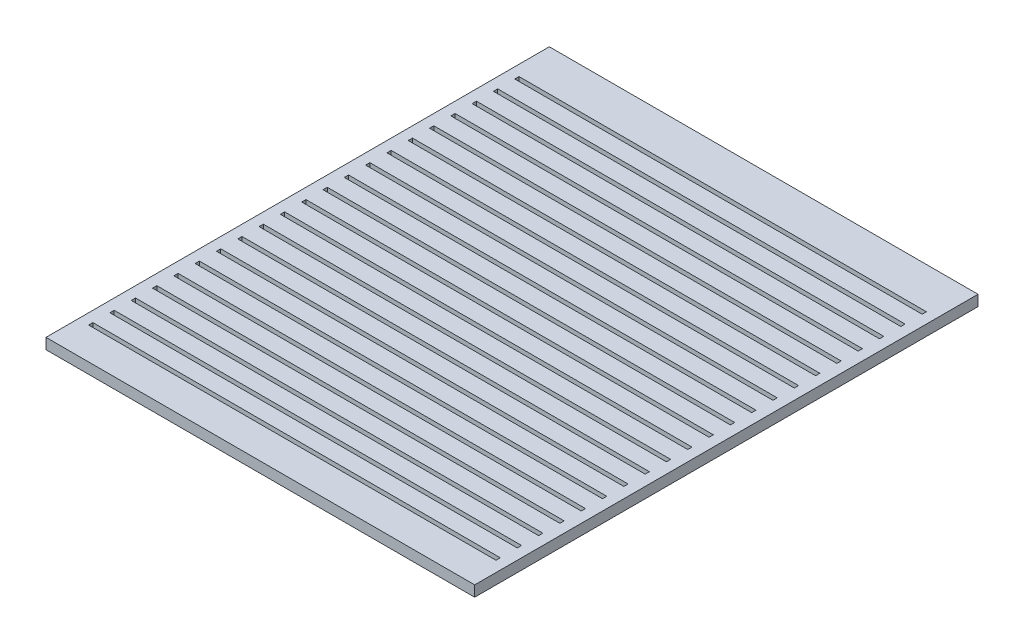
from build123d import *

# Parameters (mm, degrees)
SKETCH1_W           = 242.82
SKETCH1_H           = 287.3
BOSS_EXTRUDE1_DEPTH = 6.35
SKETCH4_W           = 255.52
SKETCH4_H           = 300
BOSS_EXTRUDE4_DEPTH = 6.4008
SKETCH5_W           = 242.82
SKETCH5_H           = 2.54
BOSS_EXTRUDE5_DEPTH = 49.5808
LPATTERN1_COUNT     = 21
LPATTERN1_PITCH     = 12.7


with BuildPart() as part:
    # Sketch1 → Boss-Extrude1 (new body)
    with BuildSketch(Plane(origin=(0, 0, 0), x_dir=(1, 0, 0), z_dir=(0, 1, 0))):
        Rectangle(SKETCH1_W, SKETCH1_H)
    extrude(amount=-BOSS_EXTRUDE1_DEPTH)

    # Sketch4 → Boss-Extrude4 (add)
    with BuildSketch(Plane(origin=(0, 0, 0), x_dir=(1, 0, 0), z_dir=(0, 1, 0))):
        Rectangle(SKETCH4_W, SKETCH4_H)
    extrude(amount=BOSS_EXTRUDE4_DEPTH)


with BuildPart() as body_2:
    # Sketch5 → Boss-Extrude5 (new body)
    with BuildSketch(Plane.XZ.offset(6.35)):
        with Locations((0, 129.68)):
            Rectangle(SKETCH5_W, SKETCH5_H)
    boss_extrude5 = extrude(amount=-BOSS_EXTRUDE5_DEPTH)


with BuildPart() as lpattern1_1:
    # LPattern1: pattern copy
    add(boss_extrude5.moved(Location(Vector(0, 0, -1) * (1 * LPATTERN1_PITCH))))


with BuildPart() as lpattern1_2:
    # LPattern1: pattern copy
    add(boss_extrude5.moved(Location(Vector(0, 0, -1) * (2 * LPATTERN1_PITCH))))


with BuildPart() as lpattern1_3:
    # LPattern1: pattern copy
    add(boss_extrude5.moved(Location(Vector(0, 0, -1) * (3 * LPATTERN1_PITCH))))


with BuildPart() as lpattern1_4:
    # LPattern1: pattern copy
    add(boss_extrude5.moved(Location(Vector(0, 0, -1) * (4 * LPATTERN1_PITCH))))


with BuildPart() as lpattern1_5:
    # LPattern1: pattern copy
    add(boss_extrude5.moved(Location(Vector(0, 0, -1) * (5 * LPATTERN1_PITCH))))


with BuildPart() as lpattern1_6:
    # LPattern1: pattern copy
    add(boss_extrude5.moved(Location(Vector(0, 0, -1) * (6 * LPATTERN1_PITCH))))


with BuildPart() as lpattern1_7:
    # LPattern1: pattern copy
    add(boss_extrude5.moved(Location(Vector(0, 0, -1) * (7 * LPATTERN1_PITCH))))


with BuildPart() as lpattern1_8:
    # LPattern1: pattern copy
    add(boss_extrude5.moved(Location(Vector(0, 0, -1) * (8 * LPATTERN1_PITCH))))


with BuildPart() as lpattern1_9:
    # LPattern1: pattern copy
    add(boss_extrude5.moved(Location(Vector(0, 0, -1) * (9 * LPATTERN1_PITCH))))


with BuildPart() as lpattern1_10:
    # LPattern1: pattern copy
    add(boss_extrude5.moved(Location(Vector(0, 0, -1) * (10 * LPATTERN1_PITCH))))


with BuildPart() as lpattern1_11:
    # LPattern1: pattern copy
    add(boss_extrude5.moved(Location(Vector(0, 0, -1) * (11 * LPATTERN1_PITCH))))


with BuildPart() as lpattern1_12:
    # LPattern1: pattern copy
    add(boss_extrude5.moved(Location(Vector(0, 0, -1) * (12 * LPATTERN1_PITCH))))


with BuildPart() as lpattern1_13:
    # LPattern1: pattern copy
    add(boss_extrude5.moved(Location(Vector(0, 0, -1) * (13 * LPATTERN1_PITCH))))


with BuildPart() as lpattern1_14:
    # LPattern1: pattern copy
    add(boss_extrude5.moved(Location(Vector(0, 0, -1) * (14 * LPATTERN1_PITCH))))


with BuildPart() as lpattern1_15:
    # LPattern1: pattern copy
    add(boss_extrude5.moved(Location(Vector(0, 0, -1) * (15 * LPATTERN1_PITCH))))


with BuildPart() as lpattern1_16:
    # LPattern1: pattern copy
    add(boss_extrude5.moved(Location(Vector(0, 0, -1) * (16 * LPATTERN1_PITCH))))


with BuildPart() as lpattern1_17:
    # LPattern1: pattern copy
    add(boss_extrude5.moved(Location(Vector(0, 0, -1) * (17 * LPATTERN1_PITCH))))


with BuildPart() as lpattern1_18:
    # LPattern1: pattern copy
    add(boss_extrude5.moved(Location(Vector(0, 0, -1) * (18 * LPATTERN1_PITCH))))


with BuildPart() as lpattern1_19:
    # LPattern1: pattern copy
    add(boss_extrude5.moved(Location(Vector(0, 0, -1) * (19 * LPATTERN1_PITCH))))


with BuildPart() as lpattern1_20:
    # LPattern1: pattern copy
    add(boss_extrude5.moved(Location(Vector(0, 0, -1) * (20 * LPATTERN1_PITCH))))


with BuildPart() as part_1:
    add(part.part)

    # Combine1: cut body 2, LPattern1_1, LPattern1_2, LPattern1_3, LPattern1_5, LPattern1_6, LPattern1_4, LPattern1_7, LPattern1_8, LPattern1_10, LPattern1_11, LPattern1_9, LPattern1_12, LPattern1_16, LPattern1_18, LPattern1_20, LPattern1_19, LPattern1_17, LPattern1_15, LPattern1_14, LPattern1_13
    add(body_2.part, mode=Mode.SUBTRACT)
    add(lpattern1_1.part, mode=Mode.SUBTRACT)
    add(lpattern1_2.part, mode=Mode.SUBTRACT)
    add(lpattern1_3.part, mode=Mode.SUBTRACT)
    add(lpattern1_5.part, mode=Mode.SUBTRACT)
    add(lpattern1_6.part, mode=Mode.SUBTRACT)
    add(lpattern1_4.part, mode=Mode.SUBTRACT)
    add(lpattern1_7.part, mode=Mode.SUBTRACT)
    add(lpattern1_8.part, mode=Mode.SUBTRACT)
    add(lpattern1_10.part, mode=Mode.SUBTRACT)
    add(lpattern1_11.part, mode=Mode.SUBTRACT)
    add(lpattern1_9.part, mode=Mode.SUBTRACT)
    add(lpattern1_12.part, mode=Mode.SUBTRACT)
    add(lpattern1_16.part, mode=Mode.SUBTRACT)
    add(lpattern1_18.part, mode=Mode.SUBTRACT)
    add(lpattern1_20.part, mode=Mode.SUBTRACT)
    add(lpattern1_19.part, mode=Mode.SUBTRACT)
    add(lpattern1_17.part, mode=Mode.SUBTRACT)
    add(lpattern1_15.part, mode=Mode.SUBTRACT)
    add(lpattern1_14.part, mode=Mode.SUBTRACT)
    add(lpattern1_13.part, mode=Mode.SUBTRACT)


solid = part_1.part
